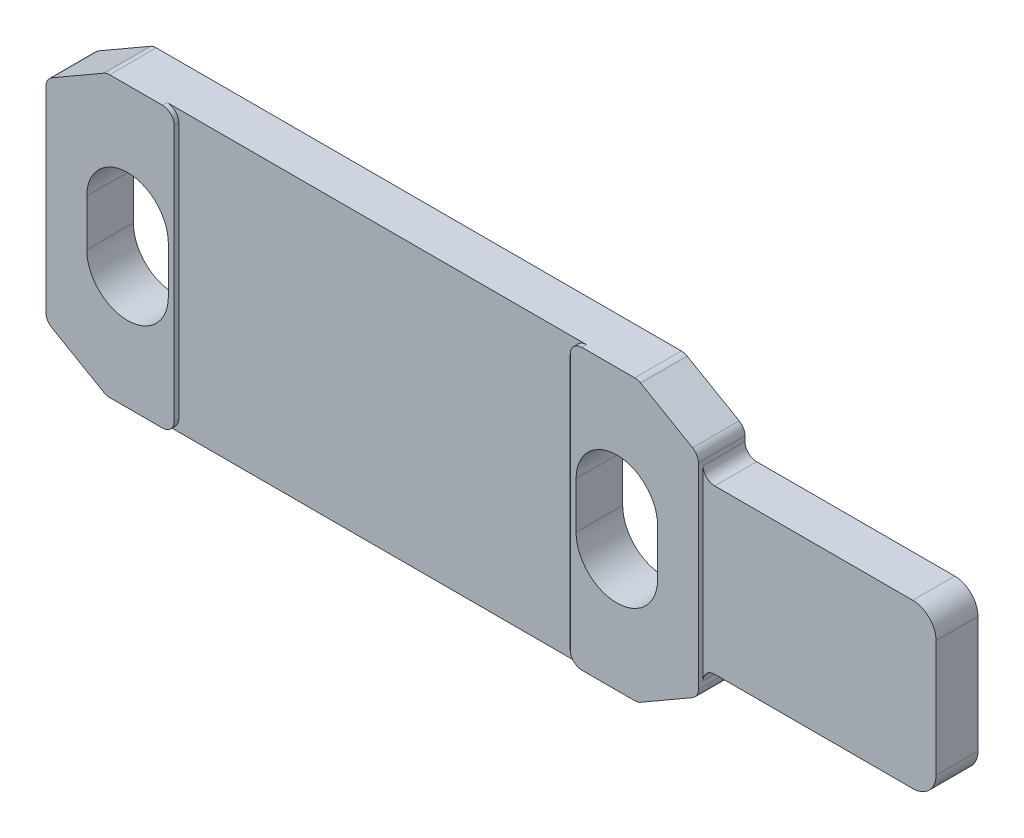
from build123d import *

# Parameters (mm, degrees)
CROQUIS4_W                   = 38
CROQUIS4_H                   = 2
SALIENTE_EXTRUIR1_DEPTH      = 6
SALIENTE_EXTRUIR1_DEPTH_BACK = 6
CROQUIS1_W                   = 10
CROQUIS1_H                   = 2.5
CORTAR_EXTRUIR2_DEPTH        = 10
CROQUIS5_W                   = 17
CROQUIS5_H                   = 12
CROQUIS5_W_2                 = 10
CORTAR_EXTRUIR3_DEPTH        = 0.2
REDONDEO1_R                  = 0.5
REDONDEO2_R                  = 0.5
REDONDEO4_R                  = 1
CHAFL_N1_SIZE                = 1.5
CHAFL_N1_SIZE2               = 2.598076211
CHAFL_N1_PART_2_SIZE         = 1.5
CHAFL_N1_PART_2_SIZE2        = 2.598076211
REDONDEO5_R                  = 0.5


with BuildPart() as part:
    # Croquis4 → Saliente-Extruir1 (new body, two sides)
    with BuildSketch(Plane(origin=(0, 0, 0), x_dir=(1, 0, 0), z_dir=(0, 1, 0))) as saliente_extruir1_sk:
        with Locations((19, 1)):
            Rectangle(CROQUIS4_W, CROQUIS4_H)
    extrude(amount=SALIENTE_EXTRUIR1_DEPTH)
    extrude(saliente_extruir1_sk.sketch, amount=-SALIENTE_EXTRUIR1_DEPTH_BACK)

    # Croquis1 → Cortar-Extruir2 (cut)
    with BuildSketch(Plane.XY):
        with Locations((33, 4.75)):
            Rectangle(CROQUIS1_W, CROQUIS1_H)
        with Locations((33, -4.75)):
            Rectangle(CROQUIS1_W, CROQUIS1_H)
        with BuildLine():
            Line((5.25, -1), (5.25, 1))
            ThreePointArc((5.25, 1), (3.5, 2.75), (1.75, 1))
            Line((1.75, 1), (1.75, -1))
            ThreePointArc((1.75, -1), (3.5, -2.75), (5.25, -1))
        make_face()
        with BuildLine():
            Line((22.75, 1), (22.75, -1))
            ThreePointArc((22.75, -1), (24.5, -2.75), (26.25, -1))
            Line((26.25, -1), (26.25, 1))
            ThreePointArc((26.25, 1), (24.5, 2.75), (22.75, 1))
        make_face()
    extrude(amount=-CORTAR_EXTRUIR2_DEPTH, mode=Mode.SUBTRACT)

    # Croquis5 → Cortar-Extruir3 (cut)
    with BuildSketch(Plane.XY):
        with Locations((14, 0)):
            Rectangle(CROQUIS5_W, CROQUIS5_H)
        with Locations((33, 0)):
            Rectangle(CROQUIS5_W_2, CROQUIS5_H)
    extrude(amount=-CORTAR_EXTRUIR3_DEPTH, mode=Mode.SUBTRACT)

    # Redondeo1
    redondeo1_edges = [part.edges().sort_by_distance(p)[0] for p in [
        (28, 3.5, -1.1),
        (28, -3.5, -1.1),
    ]]
    fillet(redondeo1_edges, radius=REDONDEO1_R)

    # Redondeo2
    redondeo2_edges = [part.edges().sort_by_distance(p)[0] for p in [
        (22.5, 6, -0.1),
        (22.5, -6, -0.1),
        (5.5, -6, -0.1),
        (5.5, 6, -0.1),
    ]]
    fillet(redondeo2_edges, radius=REDONDEO2_R)

    # Redondeo4
    redondeo4_edges = [part.edges().sort_by_distance(p)[0] for p in [
        (38, 3.5, -1.1),
        (38, -3.5, -1.1),
    ]]
    fillet(redondeo4_edges, radius=REDONDEO4_R)

    # Chaflán1
    chafl_n1_edges = [part.edges().sort_by_distance(p)[0] for p in [
        (0, -6, -1),
        (0, 6, -1),
    ]]
    chafl_n1_side = [part.faces().sort_by_distance(p)[0] for p in [
        (0, 0, -1),
    ]]
    chamfer(chafl_n1_edges, length=CHAFL_N1_SIZE, length2=CHAFL_N1_SIZE2, reference=chafl_n1_side[0])

    # Chaflán1 part 2
    chafl_n1_part_2_edges = [part.edges().sort_by_distance(p)[0] for p in [
        (28, 6, -1),
        (28, -6, -1),
    ]]
    chafl_n1_part_2_side = [part.faces().sort_by_distance(p)[0] for p in [
        (28, 5, -1.878344749),
    ]]
    chamfer(chafl_n1_part_2_edges, length=CHAFL_N1_PART_2_SIZE, length2=CHAFL_N1_PART_2_SIZE2, reference=chafl_n1_part_2_side[0])

    # Redondeo5
    redondeo5_edges = [part.edges().sort_by_distance(p)[0] for p in [
        (25.401923789, 6, -1),
        (2.598076211, 6, -1),
        (0, -4.5, -1),
        (0, 4.5, -1),
        (25.401923789, -6, -1),
        (2.598076211, -6, -1),
        (28, -4.5, -1),
        (28, 4.5, -1),
    ]]
    fillet(redondeo5_edges, radius=REDONDEO5_R)


solid = part.part
